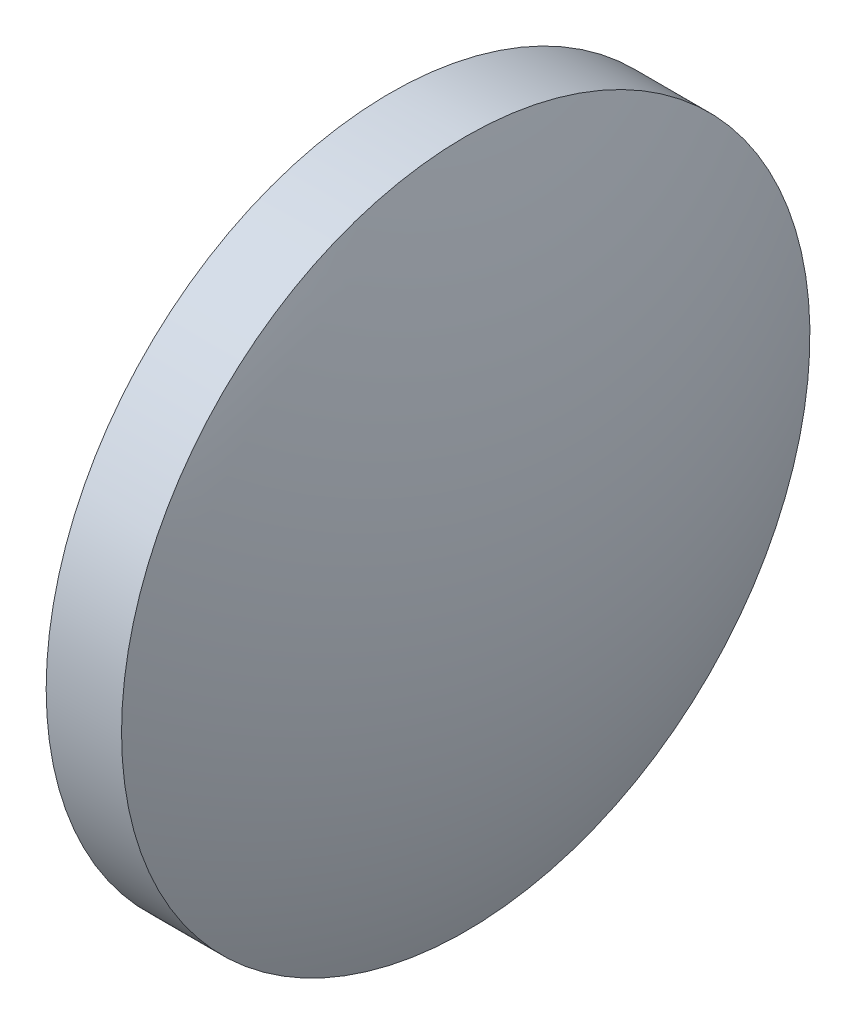
from build123d import *


with BuildPart() as part:
    # 草图1 → 旋转1 (revolve)
    with BuildSketch(Plane.XY):
        with BuildLine():
            Line((555.393121101, 188.861205983), (555.393121101, 198.861205983))
            Line((555.393121101, 198.861205983), (557.583121101, 198.861205983))
            ThreePointArc((557.583121101, 198.861205983), (559.085645733, 193.961208434), (559.593121101, 188.861205983))
            Line((559.593121101, 188.861205983), (555.393121101, 188.861205983))
        make_face()
    revolve(axis=Axis((550.736535326, 188.861205983, 0), (1, 0, 0)))


solid = part.part
